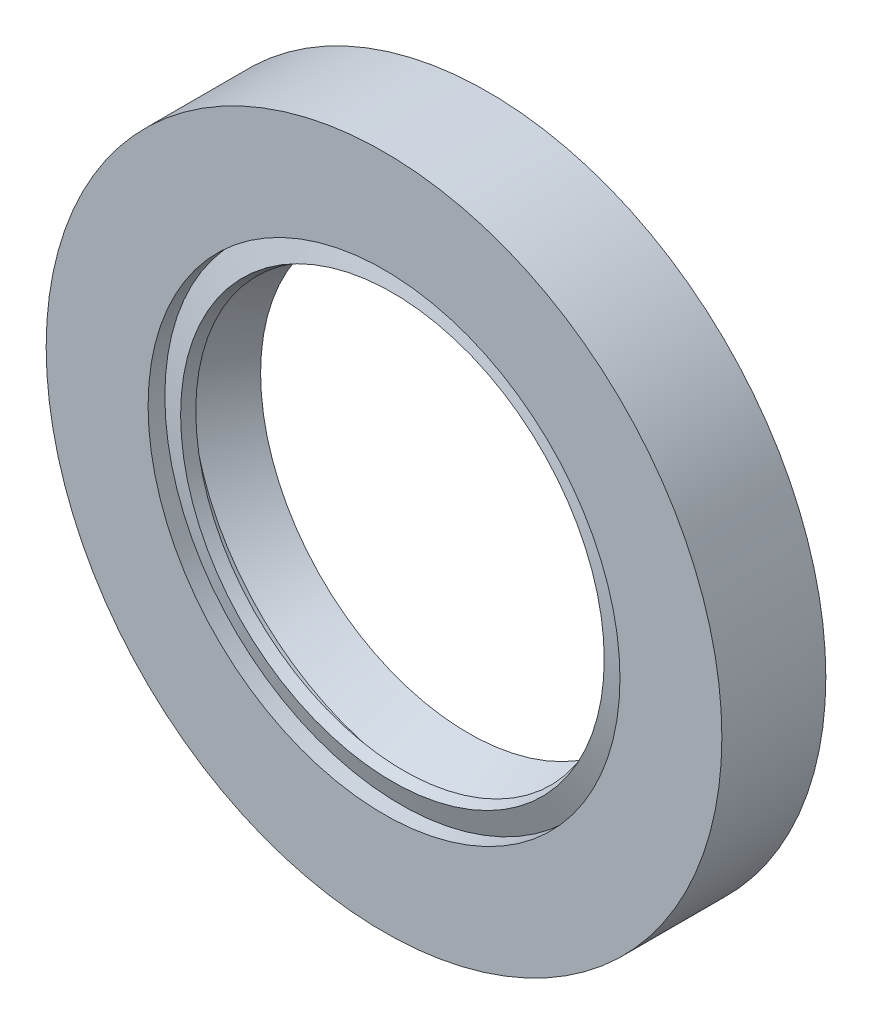
from build123d import *


with BuildPart() as part:
    # Sketch1 → Revolve1 (revolve)
    with BuildSketch(Plane(origin=(0, 0, 0), x_dir=(0, 0, -1), z_dir=(1, 0, 0))):
        Polygon((8, 26), (0, 26), (0, 18.157077096), (1.289905359, 18.157077096), (0.646560904, 16.300067014), (1.512702621, 16), (2.240654576, 18.101229145), (3.267168994, 18.101229145), (6.501757282, 16), (7.719119992, 18.162900408), (7.719119992, 19.256131168), (1.470175501, 19.256131168), (1.470175501, 24.294482866), (8, 24.294482866), align=None)
    revolve(axis=Axis((0, 0, 0), (0, 0, -1)))


solid = part.part
